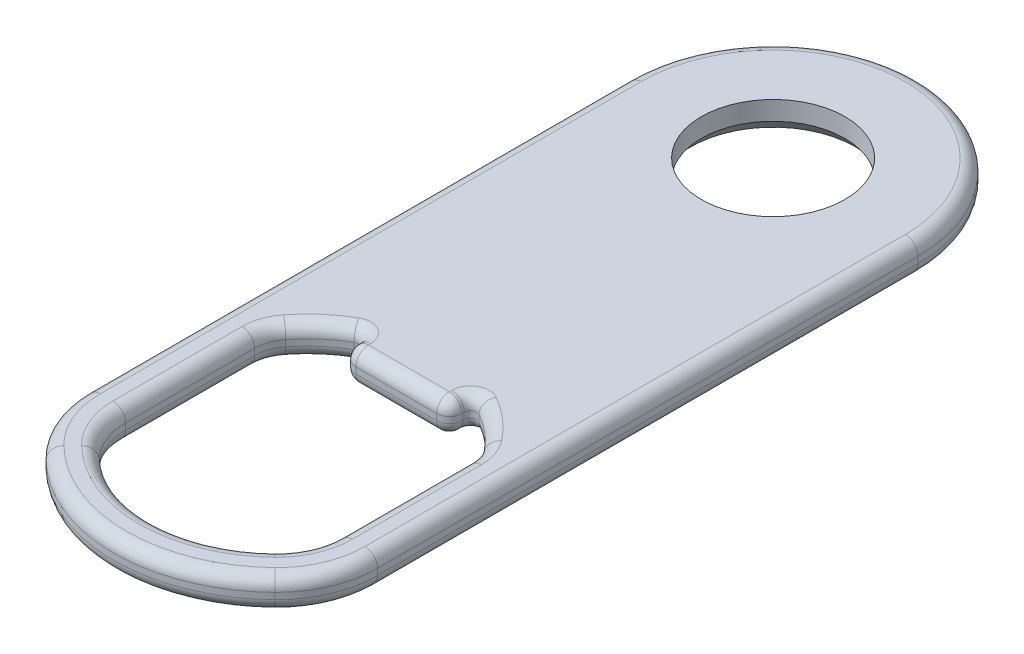
from build123d import *

# Parameters (mm, degrees)
BOSS_EXTRUDE1_DEPTH = 2.5
CUT_EXTRUDE1_DEPTH  = 10
FILLET1_R           = 1
FILLET2_R           = 8
FILLET3_R           = 5
FILLET4_R           = 3
FILLET5_R           = 0.5
FILLET6_R           = 1
FILLET7_R           = 1
CHAMFER1_SIZE       = 1
CHAMFER1_SIZE2      = 0.839099631


with BuildPart() as part:
    # Sketch3 → Boss-Extrude1 (new body)
    with BuildSketch(Plane(origin=(0, 11, 0), x_dir=(0, 0, 1), z_dir=(0, -1, 0))):
        with BuildLine():
            Line((-5.7, 0), (-12.000001825, 0))
            Line((-12.000001825, 0), (-12.000001825, 11.5))
            Line((-12.000001825, 11.5), (45.406310527, 11.5))
            ThreePointArc((45.406310527, 11.5), (50.46030749, 6.709778353), (52.322559669, 0))
            Line((52.322559669, 0), (49.322559669, 0))
            ThreePointArc((49.322559669, 0), (48.068036881, 4.857481326), (44.618252316, 8.499999508))
            Line((44.618252316, 8.499999508), (31.732809444, 8.499999508))
            ThreePointArc((31.732809444, 8.499999508), (29.503647996, 6.63570395), (27.906627074, 4.207889529))
            Line((27.906627074, 4.207889529), (29.906623676, 4.207889529))
            Line((29.906623676, 4.207889529), (29.906623676, 0))
            Line((29.906623676, 0), (5.7, 0))
            ThreePointArc((5.7, 0), (0, 5.7), (-5.7, 0))
        make_face()
    extrude(amount=-BOSS_EXTRUDE1_DEPTH)

    # Sketch5 → Cut-Extrude1 (cut)
    with BuildSketch(Plane(origin=(0, 11, 0), x_dir=(0, 0, 1), z_dir=(0, -1, 0))):
        with BuildLine():
            Line((0, 11.5), (0, 20.081542109))
            Line((0, 20.081542109), (-17.206571574, 20.081542109))
            Line((-17.206571574, 20.081542109), (-17.206571574, -3.325861619))
            Line((-17.206571574, -3.325861619), (-11.00857141, -3.325861619))
            ThreePointArc((-11.00857141, -3.325861619), (-9.23302249, 6.855749098), (0, 11.5))
        make_face()
    extrude(amount=-CUT_EXTRUDE1_DEPTH, mode=Mode.SUBTRACT)

    # Fillet1
    fillet1_edges = [part.edges().sort_by_distance(p)[0] for p in [
        (-4.207889529, 12.25, 29.906623676),
    ]]
    fillet(fillet1_edges, radius=FILLET1_R)

    # Fillet2
    fillet2_edges = [part.edges().sort_by_distance(p)[0] for p in [
        (-11.5, 12.25, 45.406310527),
    ]]
    fillet(fillet2_edges, radius=FILLET2_R)

    # Fillet3
    fillet3_edges = [part.edges().sort_by_distance(p)[0] for p in [
        (-8.499999508, 12.25, 44.618252316),
    ]]
    fillet(fillet3_edges, radius=FILLET3_R)

    # Fillet4
    fillet4_edges = [part.edges().sort_by_distance(p)[0] for p in [
        (-8.499999508, 12.25, 31.732809444),
    ]]
    fillet(fillet4_edges, radius=FILLET4_R)

    # Fillet5
    fillet5_edges = [part.edges().sort_by_distance(p)[0] for p in [
        (-4.207889529, 12.25, 27.906627074),
    ]]
    fillet(fillet5_edges, radius=FILLET5_R)

    # Fillet6
    fillet6_edges = [part.edges().sort_by_distance(p)[0] for p in [
        (-4.899665378, 11, 51.36538086),
        (-8.131727984, 11, -8.131727984),
        (-4.899665378, 13.5, 51.36538086),
        (-8.131727984, 13.5, -8.131727984),
        (-11.5, 11, 21.45040417),
        (-10.869902111, 11, 46.012808159),
        (-11.5, 13.5, 21.45040417),
        (-10.869902111, 13.5, 46.012808159),
    ]]
    fillet(fillet6_edges, radius=FILLET6_R)

    # Fillet7
    fillet7_edges = [part.edges().sort_by_distance(p)[0] for p in [
        (-1.603944764, 13.5, 29.906623676),
        (-1.603944764, 11, 29.906623676),
        (-4.207889529, 11, 28.817398931),
        (-3.91499631, 11, 29.613730457),
        (-4.207889529, 13.5, 28.817398931),
        (-3.91499631, 13.5, 29.613730457),
        (-3.764181528, 11, 48.589533472),
        (-3.764181528, 13.5, 48.589533472),
        (-8.103866337, 11, 44.856156934),
        (-8.103866337, 13.5, 44.856156934),
        (-8.499999508, 13.5, 37.784126486),
        (-8.499999508, 11, 37.784126486),
        (-8.337232062, 11, 31.68784918),
        (-8.337232062, 13.5, 31.68784918),
        (-6.534576313, 13.5, 29.414716402),
        (-6.534576313, 11, 29.414716402),
        (-4.457147388, 11, 28.295590808),
        (-4.457147388, 13.5, 28.295590808),
    ]]
    fillet(fillet7_edges, radius=FILLET7_R)

    # Chamfer1
    chamfer1_edges = [part.edges().sort_by_distance(p)[0] for p in [
        (-5.7, 11, 0),
    ]]
    chamfer1_side = [part.faces().sort_by_distance(p)[0] for p in [
        (-5.7, 12.25, 0),
    ]]
    chamfer(chamfer1_edges, length=CHAMFER1_SIZE, length2=CHAMFER1_SIZE2, reference=chamfer1_side[0])

    # Mirror1: part across plane


with BuildPart() as part_1:
    add(part.part)
    add(part.part.mirror(Plane(origin=(0, 0, 0), x_dir=(0, 0, 1), z_dir=(1, 0, 0))))


solid = part_1.part
